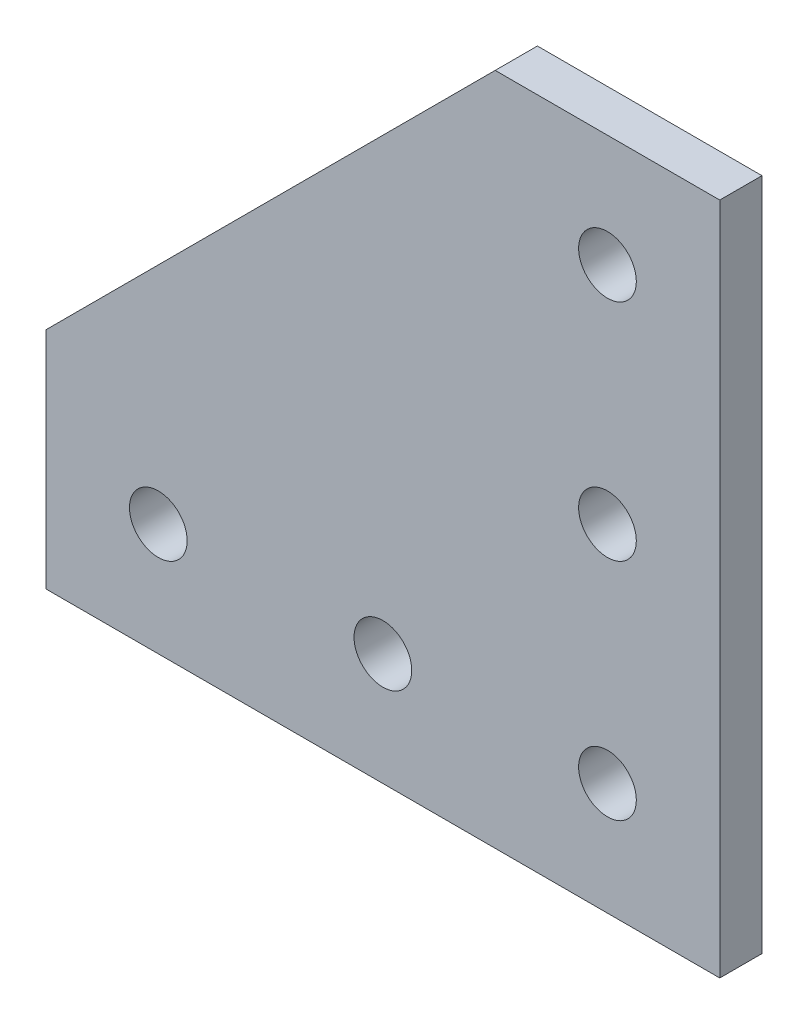
from build123d import *

# Parameters (mm, degrees)
SKETCH1_R           = 3.2639
BOSS_EXTRUDE1_DEPTH = 4.7752


with BuildPart() as part:
    # Sketch1 → Boss-Extrude1 (new body)
    with BuildSketch(Plane.XY):
        Polygon((-63.5, -12.7), (12.7, -12.7), (12.7, 63.5), (-12.7, 63.5), (-63.5, 12.7), align=None)
        with Locations((0, 50.8)):
            Circle(SKETCH1_R, mode=Mode.SUBTRACT)
        with Locations((0, 25.4)):
            Circle(SKETCH1_R, mode=Mode.SUBTRACT)
        Circle(SKETCH1_R, mode=Mode.SUBTRACT)
        with Locations((-25.4, 0)):
            Circle(SKETCH1_R, mode=Mode.SUBTRACT)
        with Locations((-50.8, 0)):
            Circle(SKETCH1_R, mode=Mode.SUBTRACT)
    extrude(amount=BOSS_EXTRUDE1_DEPTH)


solid = part.part
